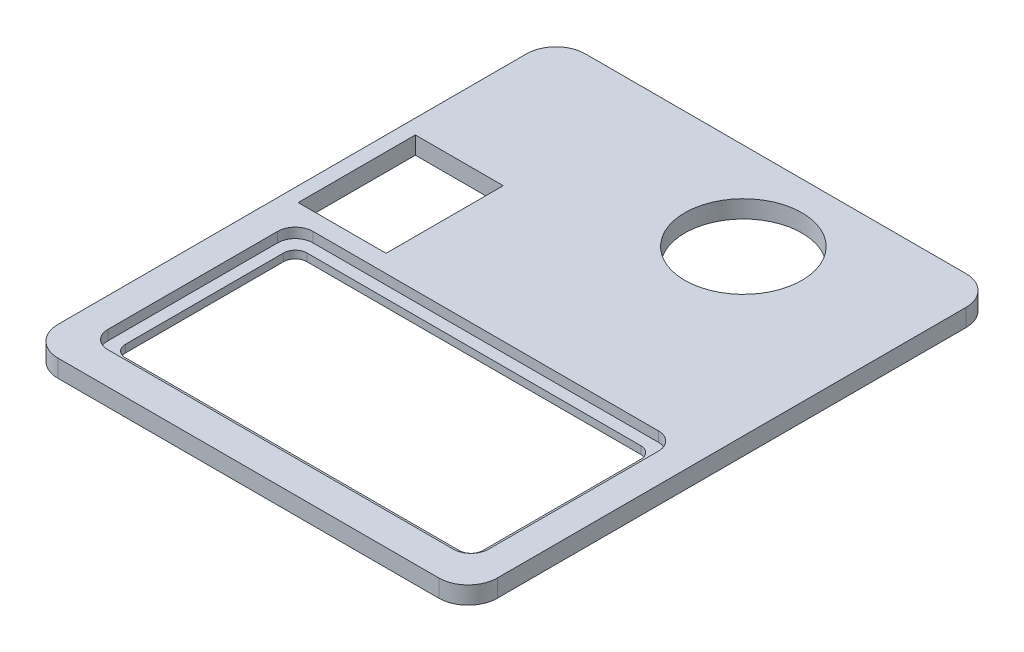
from build123d import *

# Parameters (mm, degrees)
BOSS_EXTRUDE1_DEPTH     = 3
SKETCH2_R               = 10
SKETCH2_W               = 15
SKETCH2_H               = 20
CUT_EXTRUDE4_DEPTH      = 7
CUT_EXTRUDE4_DEPTH_BACK = 3
SKETCH6_W               = 65
SKETCH6_H               = 35
BOSS_EXTRUDE5_DEPTH     = 1.3


with BuildPart() as part:
    # Sketch1 → Boss-Extrude1 (new body)
    with BuildSketch(Plane(origin=(0, 0, 0), x_dir=(1, 0, 0), z_dir=(0, 1, 0))):
        with BuildLine():
            Line((5, 0), (70, 0))
            ThreePointArc((70, 0), (73.535533906, 1.464466094), (75, 5))
            Line((75, 5), (75, 85))
            ThreePointArc((75, 85), (73.535533906, 88.535533906), (70, 90))
            Line((70, 90), (5, 90))
            ThreePointArc((5, 90), (1.464466094, 88.535533906), (0, 85))
            Line((0, 85), (0, 5))
            ThreePointArc((0, 5), (1.464466094, 1.464466094), (5, 0))
        make_face()
    extrude(amount=BOSS_EXTRUDE1_DEPTH)

    # Sketch2 → Cut-Extrude4 (cut, two sides)
    with BuildSketch(Plane(origin=(0, 0, 0), x_dir=(1, 0, 0), z_dir=(0, 1, 0))) as cut_extrude4_sk:
        with Locations((47, 75)):
            Circle(SKETCH2_R)
        with BuildLine():
            Line((8, 5.5), (67, 5.5))
            ThreePointArc((67, 5.5), (69.121320344, 6.378679656), (70, 8.5))
            Line((70, 8.5), (70, 37.5))
            ThreePointArc((70, 37.5), (69.121320344, 39.621320344), (67, 40.5))
            Line((67, 40.5), (8, 40.5))
            ThreePointArc((8, 40.5), (5.878679656, 39.621320344), (5, 37.5))
            Line((5, 37.5), (5, 8.5))
            ThreePointArc((5, 8.5), (5.878679656, 6.378679656), (8, 5.5))
        make_face()
        with Locations((10, 53.5)):
            Rectangle(SKETCH2_W, SKETCH2_H)
    extrude(amount=CUT_EXTRUDE4_DEPTH, mode=Mode.SUBTRACT)
    extrude(cut_extrude4_sk.sketch, amount=-CUT_EXTRUDE4_DEPTH_BACK, mode=Mode.SUBTRACT)

    # Sketch6 → Boss-Extrude5 (add)
    with BuildSketch(Plane(origin=(0, 0, 0), x_dir=(1, 0, 0), z_dir=(0, 1, 0))):
        with Locations((37.5, 23)):
            Rectangle(SKETCH6_W, SKETCH6_H)
        with BuildLine():
            Line((9, 38.5), (66, 38.5))
            ThreePointArc((66, 38.5), (67.414213562, 37.914213562), (68, 36.5))
            Line((68, 36.5), (68, 9.5))
            ThreePointArc((68, 9.5), (67.414213562, 8.085786438), (66, 7.5))
            Line((66, 7.5), (9, 7.5))
            ThreePointArc((9, 7.5), (7.585786438, 8.085786438), (7, 9.5))
            Line((7, 9.5), (7, 36.5))
            ThreePointArc((7, 36.5), (7.585786438, 37.914213562), (9, 38.5))
        make_face(mode=Mode.SUBTRACT)
    extrude(amount=BOSS_EXTRUDE5_DEPTH)


solid = part.part
